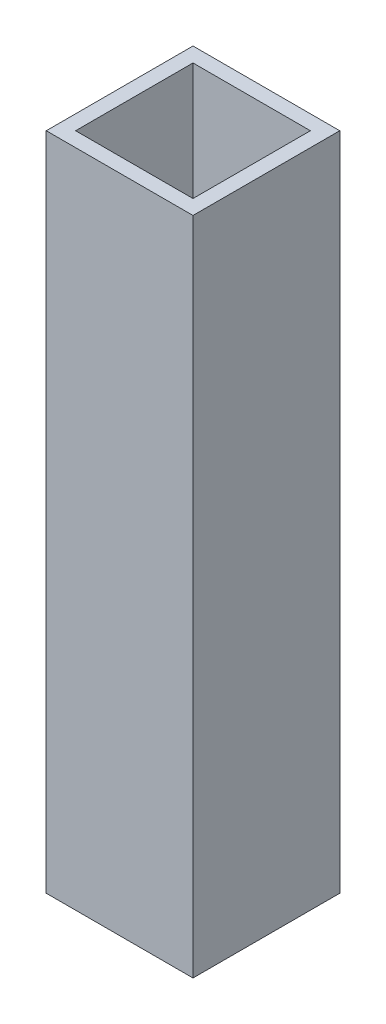
from build123d import *

# Parameters (mm, degrees)
SKETCH1_W           = 25.4
SKETCH1_H           = 25.4
SKETCH1_W_2         = 20.32
SKETCH1_H_2         = 20.32
BOSS_EXTRUDE1_DEPTH = 114.3


with BuildPart() as part:
    # Sketch1 → Boss-Extrude1 (new body)
    with BuildSketch(Plane(origin=(0, 0, 0), x_dir=(1, 0, 0), z_dir=(0, 1, 0))):
        Rectangle(SKETCH1_W, SKETCH1_H)
        Rectangle(SKETCH1_W_2, SKETCH1_H_2, mode=Mode.SUBTRACT)
    extrude(amount=BOSS_EXTRUDE1_DEPTH)


solid = part.part
